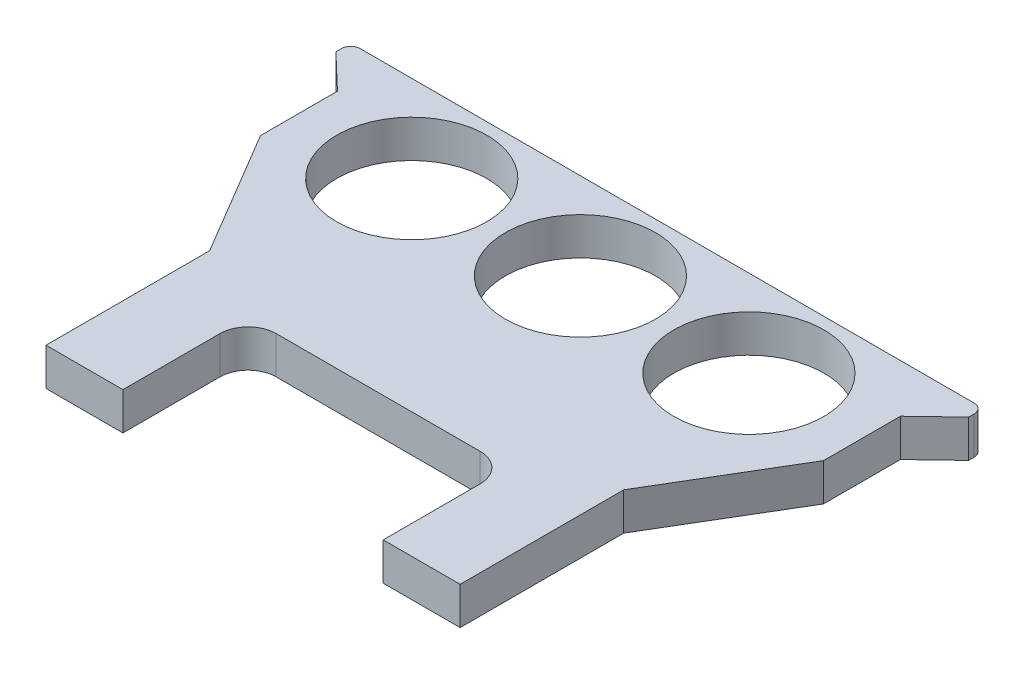
from build123d import *

# Parameters (mm, degrees)
ESTRUSIONE_ESTRUSIONE8_DEPTH = 2
SCHIZZO8_R                   = 4
TAGLIO_ESTRUSIONE6_DEPTH     = 2
SCHIZZO15_R                  = 4
TAGLIO_ESTRUSIONE7_DEPTH     = 2
SCHIZZO16_R                  = 4
TAGLIO_ESTRUSIONE9_DEPTH     = 2


with BuildPart() as part:
    # Schizzo2 → Estrusione-Estrusione8 (new body)
    with BuildSketch(Plane(origin=(0, 0, 0), x_dir=(1, 0, 0), z_dir=(0, 1, 0))):
        with BuildLine():
            Line((-6.935, -4.36), (-6.935, 0.81))
            ThreePointArc((-6.935, 0.81), (-6.495660172, 1.870660172), (-5.435, 2.31))
            Line((-5.435, 2.31), (5.435, 2.31))
            ThreePointArc((5.435, 2.31), (6.495660172, 1.870660172), (6.935, 0.81))
            Line((6.935, 0.81), (6.935, -4.36))
            Line((6.935, -4.36), (11.035, -4.36))
            Line((11.035, -4.36), (11.035, 4.36))
            Line((11.035, 4.36), (15.01, 11.03))
            Line((15.01, 11.03), (15.01, 15.13))
            Line((15.01, 15.13), (16.868239421, 16.905343982))
            Line((16.868239421, 16.905343982), (16.868239421, 17.200505886))
            ThreePointArc((16.868239421, 17.200505886), (16.721792811, 17.554059277), (16.368239421, 17.700505886))
            Line((16.368239421, 17.700505886), (-14.992624707, 17.700505886))
            Line((-14.992624707, 17.700505886), (-16.351038686, 17.700505886))
            ThreePointArc((-16.351038686, 17.700505886), (-16.704592076, 17.554059277), (-16.851038686, 17.200505886))
            Line((-16.851038686, 17.200505886), (-16.851038686, 16.905667142))
            Line((-16.851038686, 16.905667142), (-14.992624707, 15.130505886))
            Line((-14.992624707, 15.130505886), (-14.992624707, 11.030505886))
            Line((-14.992624707, 11.030505886), (-11.035, 4.36))
            Line((-11.035, 4.36), (-11.035, -4.36))
            Line((-11.035, -4.36), (-6.935, -4.36))
        make_face()
    extrude(amount=ESTRUSIONE_ESTRUSIONE8_DEPTH)

    # Schizzo8 → Taglio-Estrusione6 (cut)
    with BuildSketch(Plane(origin=(0, 0, 0), x_dir=(1, 0, 0), z_dir=(0, 1, 0))):
        with Locations((8.985, 13.08010159)):
            Circle(SCHIZZO8_R)
    extrude(amount=TAGLIO_ESTRUSIONE6_DEPTH, mode=Mode.SUBTRACT)

    # Schizzo15 → Taglio-Estrusione7 (cut)
    with BuildSketch(Plane(origin=(0, 0, 0), x_dir=(1, 0, 0), z_dir=(0, 1, 0))):
        with Locations((0.00688301, 13.08)):
            Circle(SCHIZZO15_R)
    extrude(amount=TAGLIO_ESTRUSIONE7_DEPTH, mode=Mode.SUBTRACT)

    # Schizzo16 → Taglio-Estrusione9 (cut)
    with BuildSketch(Plane(origin=(0, 0, 0), x_dir=(1, 0, 0), z_dir=(0, 1, 0))):
        with Locations((-8.985, 13.080505886)):
            Circle(SCHIZZO16_R)
    extrude(amount=TAGLIO_ESTRUSIONE9_DEPTH, mode=Mode.SUBTRACT)


solid = part.part
